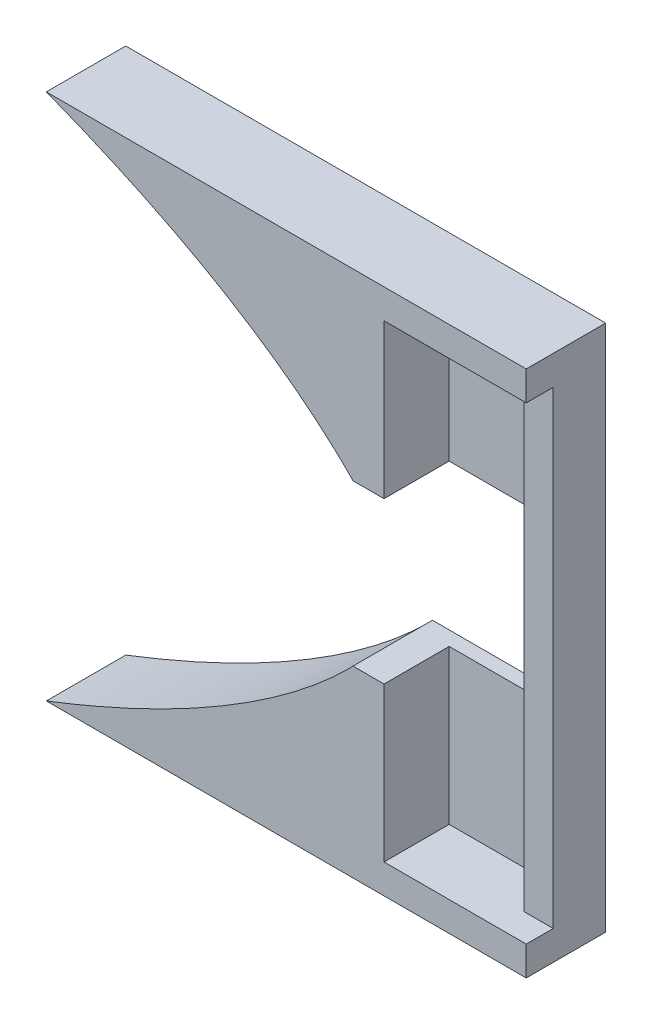
from build123d import *

# Parameters (mm, degrees)
BOSS_EXTRUDE1_DEPTH = 3.3
SKETCH2_W           = 7.1
SKETCH2_H           = 9.7
BOSS_EXTRUDE2_DEPTH = 0.9
BOSS_EXTRUDE3_DEPTH = 1.7


with BuildPart() as part:
    # Sketch1 → Boss-Extrude1 (new body)
    with BuildSketch(Plane.XY):
        with BuildLine():
            Line((57.315911484, 16.6), (34.644864201, 16.6))
            add(Edge.make_bspline(
                [(38.29556789, 15.1), (37.098221073, 15.62404419), (35.878697194, 16.123957864), (34.644864201, 16.6)],
                knots=[0.303308677, 0.303308677, 0.303308677, 0.303308677, 0.363483136, 0.363483136, 0.363483136, 0.363483136], degree=3))
            Line((38.29556789, 15.1), (58.028235271, 15.1))
            add(Edge.make_bspline(
                [(58.028235271, 15.1), (57.812878468, 15.594922403), (57.575647456, 16.094915482), (57.315911484, 16.6)],
                knots=[1.426893222, 1.426893222, 1.426893222, 1.426893222, 1.452839647, 1.452839647, 1.452839647, 1.452839647], degree=3))
        make_face()
        with BuildLine():
            Line((64.85, 16.6), (57.315911484, 16.6))
            add(Edge.make_bspline(
                [(58.028235271, 15.1), (57.812878468, 15.594922403), (57.575647456, 16.094915482), (57.315911484, 16.6)],
                knots=[1.426893222, 1.426893222, 1.426893222, 1.426893222, 1.452839647, 1.452839647, 1.452839647, 1.452839647], degree=3))
            Line((58.028235271, 15.1), (63.35, 15.1))
            Line((63.35, 15.1), (63.35, 7.210091206))
            add(Edge.make_bspline(
                [(63.35, 7.210091206), (63.846734552, 7.128818212), (64.346729159, 7.047274139), (64.85, 6.965459519)],
                knots=[2.014857734, 2.014857734, 2.014857734, 2.014857734, 2.022509587, 2.022509587, 2.022509587, 2.022509587], degree=3))
            Line((64.85, 6.965459519), (64.85, 16.6))
        make_face()
        with BuildLine():
            add(Edge.make_bspline(
                [(55.9, -8.449641541), (53.219410431, -8.903431774), (50.645090889, -9.348060462), (48.173910637, -9.783424554)],
                knots=[-0.975271105, -0.975271105, -0.975271105, -0.975271105, -0.931011535, -0.931011535, -0.931011535, -0.931011535], degree=3))
            add(Edge.make_bspline(
                [(48.17391063, -9.783424538), (50.235379211, -8.397456689), (52.10175446, -6.904847258), (53.703300859, -5.303300859)],
                knots=[0.875469321, 0.875469321, 0.875469321, 0.875469321, 1, 1, 1, 1], degree=3))
            add(Edge.make_bspline(
                [(38.29556789, -15.1), (44.330780941, -12.458561206), (49.802551874, -9.204049844), (53.703300859, -5.303300859)],
                knots=[0.696691323, 0.696691323, 0.696691323, 0.696691323, 1, 1, 1, 1], degree=3))
            Line((38.29556789, -15.1), (58.028235271, -15.1))
            add(Edge.make_bspline(
                [(58.028235271, -15.1), (58.079123886, -14.983050292), (58.128791104, -14.866383717), (58.177245249, -14.75)],
                knots=[-0.426893222, -0.426893222, -0.426893222, -0.426893222, -0.420762106, -0.420762106, -0.420762106, -0.420762106], degree=3))
            Line((58.177245249, -14.75), (55.9, -14.75))
            Line((55.9, -14.75), (55.9, -8.449641541))
        make_face()
        with BuildLine():
            add(Edge.make_bspline(
                [(48.17391063, -9.783424538), (50.235379211, -8.397456689), (52.10175446, -6.904847258), (53.703300859, -5.303300859)],
                knots=[0.875469321, 0.875469321, 0.875469321, 0.875469321, 1, 1, 1, 1], degree=3))
            add(Edge.make_bspline(
                [(55.9, -8.449641541), (53.219410431, -8.903431774), (50.645090889, -9.348060462), (48.173910637, -9.783424554)],
                knots=[-0.975271105, -0.975271105, -0.975271105, -0.975271105, -0.931011535, -0.931011535, -0.931011535, -0.931011535], degree=3))
            Line((55.9, -8.449641541), (55.9, -5.05))
            Line((55.9, -5.05), (53.953496898, -5.05))
            add(Edge.make_bspline(
                [(53.703300859, -5.303300859), (53.787433741, -5.219167977), (53.87083579, -5.134734468), (53.953496898, -5.05)],
                knots=[1, 1, 1, 1, 1.00654188, 1.00654188, 1.00654188, 1.00654188], degree=3))
        make_face()
        with BuildLine():
            add(Edge.make_bspline(
                [(53.703300859, 5.303300859), (52.10175446, 6.904847258), (50.235379211, 8.397456689), (48.17391063, 9.783424538)],
                knots=[0, 0, 0, 0, 0.124530679, 0.124530679, 0.124530679, 0.124530679], degree=3))
            add(Edge.make_bspline(
                [(53.953496898, 5.05), (53.87083579, 5.134734468), (53.787433741, 5.219167977), (53.703300859, 5.303300859)],
                knots=[-0.00654188, -0.00654188, -0.00654188, -0.00654188, 0, 0, 0, 0], degree=3))
            Line((53.953496898, 5.05), (55.9, 5.05))
            Line((55.9, 5.05), (55.9, 8.449641541))
            add(Edge.make_bspline(
                [(48.173910637, 9.783424554), (50.645090889, 9.348060462), (53.219410431, 8.903431774), (55.9, 8.449641541)],
                knots=[1.931011535, 1.931011535, 1.931011535, 1.931011535, 1.975271105, 1.975271105, 1.975271105, 1.975271105], degree=3))
        make_face()
        with BuildLine():
            add(Edge.make_bspline(
                [(53.953496898, 5.05), (53.87083579, 5.134734468), (53.787433741, 5.219167977), (53.703300859, 5.303300859)],
                knots=[-0.00654188, -0.00654188, -0.00654188, -0.00654188, 0, 0, 0, 0], degree=3))
            ThreePointArc((53.703300859, 5.303300859), (53.825650241, 5.178061362), (53.945042831, 5.05))
            Line((53.945042831, 5.05), (53.953496898, 5.05))
        make_face()
        with BuildLine():
            Line((58.028235271, 15.1), (38.29556789, 15.1))
            add(Edge.make_bspline(
                [(48.17391063, 9.783424538), (45.214437276, 11.773139517), (41.852878937, 13.543067491), (38.29556789, 15.1)],
                knots=[0.124530679, 0.124530679, 0.124530679, 0.124530679, 0.303308677, 0.303308677, 0.303308677, 0.303308677], degree=3))
            add(Edge.make_bspline(
                [(48.173910637, 9.783424554), (50.645090889, 9.348060462), (53.219410431, 8.903431774), (55.9, 8.449641541)],
                knots=[1.931011535, 1.931011535, 1.931011535, 1.931011535, 1.975271105, 1.975271105, 1.975271105, 1.975271105], degree=3))
            Line((55.9, 8.449641541), (55.9, 14.75))
            Line((55.9, 14.75), (58.177245249, 14.75))
            add(Edge.make_bspline(
                [(58.177245249, 14.75), (58.128791104, 14.866383717), (58.079123886, 14.983050292), (58.028235271, 15.1)],
                knots=[1.420762106, 1.420762106, 1.420762106, 1.420762106, 1.426893222, 1.426893222, 1.426893222, 1.426893222], degree=3))
        make_face()
        with BuildLine():
            Line((63.35, 15.1), (58.028235271, 15.1))
            add(Edge.make_bspline(
                [(58.177245249, 14.75), (58.128791104, 14.866383717), (58.079123886, 14.983050292), (58.028235271, 15.1)],
                knots=[1.420762106, 1.420762106, 1.420762106, 1.420762106, 1.426893222, 1.426893222, 1.426893222, 1.426893222], degree=3))
            Line((58.177245249, 14.75), (63, 14.75))
            Line((63, 14.75), (63, 7.267399796))
            add(Edge.make_bspline(
                [(63, 7.267399796), (63.116486418, 7.248311937), (63.233153014, 7.229209071), (63.35, 7.210091206)],
                knots=[2.013057787, 2.013057787, 2.013057787, 2.013057787, 2.014857734, 2.014857734, 2.014857734, 2.014857734], degree=3))
            Line((63.35, 7.210091206), (63.35, 15.1))
        make_face()
        with BuildLine():
            add(Edge.make_bspline(
                [(34.644864201, -16.6), (35.878697194, -16.123957864), (37.098221074, -15.62404419), (38.29556789, -15.1)],
                knots=[0.636516864, 0.636516864, 0.636516864, 0.636516864, 0.696691323, 0.696691323, 0.696691323, 0.696691323], degree=3))
            Line((34.644864201, -16.6), (57.315911484, -16.6))
            add(Edge.make_bspline(
                [(57.315911484, -16.6), (57.575647456, -16.094915482), (57.812878468, -15.594922403), (58.028235271, -15.1)],
                knots=[-0.452839647, -0.452839647, -0.452839647, -0.452839647, -0.426893222, -0.426893222, -0.426893222, -0.426893222], degree=3))
            Line((58.028235271, -15.1), (38.29556789, -15.1))
        make_face()
        with BuildLine():
            Line((64.85, -6.965459519), (64.85, 6.965459519))
            add(Edge.make_bspline(
                [(63.35, 7.210091206), (63.846734552, 7.128818212), (64.346729159, 7.047274139), (64.85, 6.965459519)],
                knots=[2.014857734, 2.014857734, 2.014857734, 2.014857734, 2.022509587, 2.022509587, 2.022509587, 2.022509587], degree=3))
            Line((63.35, 7.210091206), (63.35, -7.210091206))
            add(Edge.make_bspline(
                [(64.85, -6.965459519), (64.346729159, -7.047274139), (63.846734552, -7.128818212), (63.35, -7.210091206)],
                knots=[-1.022509587, -1.022509587, -1.022509587, -1.022509587, -1.014857734, -1.014857734, -1.014857734, -1.014857734], degree=3))
        make_face()
        with BuildLine():
            add(Edge.make_bspline(
                [(57.315911484, -16.6), (57.575647456, -16.094915482), (57.812878468, -15.594922403), (58.028235271, -15.1)],
                knots=[-0.452839647, -0.452839647, -0.452839647, -0.452839647, -0.426893222, -0.426893222, -0.426893222, -0.426893222], degree=3))
            Line((57.315911484, -16.6), (64.85, -16.6))
            Line((64.85, -16.6), (64.85, -6.965459519))
            add(Edge.make_bspline(
                [(64.85, -6.965459519), (64.346729159, -7.047274139), (63.846734552, -7.128818212), (63.35, -7.210091206)],
                knots=[-1.022509587, -1.022509587, -1.022509587, -1.022509587, -1.014857734, -1.014857734, -1.014857734, -1.014857734], degree=3))
            Line((63.35, -7.210091206), (63.35, -15.1))
            Line((63.35, -15.1), (58.028235271, -15.1))
        make_face()
        with BuildLine():
            Line((63.35, -7.210091206), (63.35, 7.210091206))
            add(Edge.make_bspline(
                [(63, 7.267399796), (63.116486418, 7.248311937), (63.233153014, 7.229209071), (63.35, 7.210091206)],
                knots=[2.013057787, 2.013057787, 2.013057787, 2.013057787, 2.014857734, 2.014857734, 2.014857734, 2.014857734], degree=3))
            Line((63, 7.267399796), (63, -7.267399796))
            add(Edge.make_bspline(
                [(63.35, -7.210091206), (63.233153014, -7.229209071), (63.116486418, -7.248311937), (63, -7.267399796)],
                knots=[-1.014857734, -1.014857734, -1.014857734, -1.014857734, -1.013057787, -1.013057787, -1.013057787, -1.013057787], degree=3))
        make_face()
        with BuildLine():
            Line((53.953496898, -5.05), (53.945042831, -5.05))
            ThreePointArc((53.945042831, -5.05), (53.825650241, -5.178061362), (53.703300859, -5.303300859))
            add(Edge.make_bspline(
                [(53.703300859, -5.303300859), (53.787433741, -5.219167977), (53.87083579, -5.134734468), (53.953496898, -5.05)],
                knots=[1, 1, 1, 1, 1.00654188, 1.00654188, 1.00654188, 1.00654188], degree=3))
        make_face()
        with BuildLine():
            add(Edge.make_bspline(
                [(58.028235271, -15.1), (58.079123886, -14.983050292), (58.128791104, -14.866383717), (58.177245249, -14.75)],
                knots=[-0.426893222, -0.426893222, -0.426893222, -0.426893222, -0.420762106, -0.420762106, -0.420762106, -0.420762106], degree=3))
            Line((58.028235271, -15.1), (63.35, -15.1))
            Line((63.35, -15.1), (63.35, -7.210091206))
            add(Edge.make_bspline(
                [(63.35, -7.210091206), (63.233153014, -7.229209071), (63.116486418, -7.248311937), (63, -7.267399796)],
                knots=[-1.014857734, -1.014857734, -1.014857734, -1.014857734, -1.013057787, -1.013057787, -1.013057787, -1.013057787], degree=3))
            Line((63, -7.267399796), (63, -14.75))
            Line((63, -14.75), (58.177245249, -14.75))
        make_face()
    extrude(amount=-BOSS_EXTRUDE1_DEPTH)

    # Sketch2 → Boss-Extrude2 (add)
    with BuildSketch(Plane(origin=(0, 0, -3.3), x_dir=(-1, 0, 0), z_dir=(0, 0, -1))):
        with Locations((-59.45, -9.9)):
            Rectangle(SKETCH2_W, SKETCH2_H)
        with Locations((-59.45, 9.9)):
            Rectangle(SKETCH2_W, SKETCH2_H)
    extrude(amount=-BOSS_EXTRUDE2_DEPTH)

    # Sketch3 → Boss-Extrude3 (add)
    with BuildSketch(Plane.XY):
        with BuildLine():
            Line((58.177245249, 14.75), (63, 14.75))
            Line((63, 14.75), (64.85, 14.75))
            Line((64.85, 14.75), (64.85, 16.6))
            Line((64.85, 16.6), (57.315911484, 16.6))
            add(Edge.make_bspline(
                [(57.315911484, 16.6), (57.637022826, 15.975564476), (57.923736792, 15.358910886), (58.177245249, 14.75)],
                knots=[0.183677217, 0.183677217, 0.183677217, 0.183677217, 0.215754758, 0.215754758, 0.215754758, 0.215754758], degree=3))
        make_face()
        with BuildLine():
            Line((57.315911484, 16.6), (34.644864201, 16.6))
            add(Edge.make_bspline(
                [(34.644864201, 16.6), (39.544408477, 14.709639199), (44.218315219, 12.442852923), (48.173910631, 9.783424537)],
                knots=[0, 0, 0, 0, 0.238952457, 0.238952457, 0.238952457, 0.238952457], degree=3))
            add(Edge.make_bspline(
                [(55.9, 8.449641541), (53.219410431, 8.903431774), (50.64509089, 9.348060461), (48.173910638, 9.783424554)],
                knots=[-1.611787969, -1.611787969, -1.611787969, -1.611787969, -1.567528399, -1.567528399, -1.567528399, -1.567528399], degree=3))
            Line((55.9, 8.449641541), (55.9, 14.75))
            Line((55.9, 14.75), (58.177245249, 14.75))
            add(Edge.make_bspline(
                [(57.315911484, 16.6), (57.637022826, 15.975564476), (57.923736792, 15.358910886), (58.177245249, 14.75)],
                knots=[0.183677217, 0.183677217, 0.183677217, 0.183677217, 0.215754758, 0.215754758, 0.215754758, 0.215754758], degree=3))
        make_face()
        with BuildLine():
            Line((55.9, 5.05), (55.9, 8.449641541))
            add(Edge.make_bspline(
                [(55.9, 8.449641541), (53.219410431, 8.903431774), (50.64509089, 9.348060461), (48.173910638, 9.783424554)],
                knots=[-1.611787969, -1.611787969, -1.611787969, -1.611787969, -1.567528399, -1.567528399, -1.567528399, -1.567528399], degree=3))
            add(Edge.make_bspline(
                [(48.173910631, 9.783424537), (50.235379212, 8.397456689), (52.10175446, 6.904847257), (53.703300859, 5.303300859)],
                knots=[0.238952457, 0.238952457, 0.238952457, 0.238952457, 0.363483136, 0.363483136, 0.363483136, 0.363483136], degree=3))
            add(Edge.make_bspline(
                [(53.703300859, 5.303300859), (53.787433741, 5.219167977), (53.87083579, 5.134734468), (53.953496898, 5.05)],
                knots=[0.363483136, 0.363483136, 0.363483136, 0.363483136, 0.370025016, 0.370025016, 0.370025016, 0.370025016], degree=3))
            Line((53.953496898, 5.05), (55.9, 5.05))
        make_face()
        with BuildLine():
            Line((64.85, -14.75), (63, -14.75))
            Line((63, -14.75), (58.177245249, -14.75))
            add(Edge.make_bspline(
                [(58.177245249, -14.75), (57.923736792, -15.358910886), (57.637022826, -15.975564476), (57.315911484, -16.6)],
                knots=[0.784245242, 0.784245242, 0.784245242, 0.784245242, 0.816322783, 0.816322783, 0.816322783, 0.816322783], degree=3))
            Line((57.315911484, -16.6), (64.85, -16.6))
            Line((64.85, -16.6), (64.85, -14.75))
        make_face()
        with BuildLine():
            add(Edge.make_bspline(
                [(53.703300859, 5.303300859), (53.787433741, 5.219167977), (53.87083579, 5.134734468), (53.953496898, 5.05)],
                knots=[0.363483136, 0.363483136, 0.363483136, 0.363483136, 0.370025016, 0.370025016, 0.370025016, 0.370025016], degree=3))
            ThreePointArc((53.703300859, 5.303300859), (53.825650241, 5.178061362), (53.945042831, 5.05))
            Line((53.945042831, 5.05), (53.953496898, 5.05))
        make_face()
        with BuildLine():
            add(Edge.make_bspline(
                [(53.953496898, -5.05), (53.87083579, -5.134734468), (53.787433741, -5.219167977), (53.703300859, -5.303300859)],
                knots=[0.629974984, 0.629974984, 0.629974984, 0.629974984, 0.636516864, 0.636516864, 0.636516864, 0.636516864], degree=3))
            Line((53.953496898, -5.05), (53.945042831, -5.05))
            ThreePointArc((53.945042831, -5.05), (53.825650241, -5.178061362), (53.703300859, -5.303300859))
        make_face()
        with BuildLine():
            add(Edge.make_bspline(
                [(48.173910631, -9.783424537), (44.218315219, -12.442852923), (39.544408477, -14.709639199), (34.644864201, -16.6)],
                knots=[0.761047543, 0.761047543, 0.761047543, 0.761047543, 1, 1, 1, 1], degree=3))
            Line((34.644864201, -16.6), (57.315911484, -16.6))
            add(Edge.make_bspline(
                [(58.177245249, -14.75), (57.923736792, -15.358910886), (57.637022826, -15.975564476), (57.315911484, -16.6)],
                knots=[0.784245242, 0.784245242, 0.784245242, 0.784245242, 0.816322783, 0.816322783, 0.816322783, 0.816322783], degree=3))
            Line((58.177245249, -14.75), (55.9, -14.75))
            Line((55.9, -14.75), (55.9, -8.449641541))
            add(Edge.make_bspline(
                [(48.173910638, -9.783424554), (50.64509089, -9.348060461), (53.219410431, -8.903431774), (55.9, -8.449641541)],
                knots=[2.567528399, 2.567528399, 2.567528399, 2.567528399, 2.611787969, 2.611787969, 2.611787969, 2.611787969], degree=3))
        make_face()
        with BuildLine():
            Line((55.9, -5.05), (53.953496898, -5.05))
            add(Edge.make_bspline(
                [(53.953496898, -5.05), (53.87083579, -5.134734468), (53.787433741, -5.219167977), (53.703300859, -5.303300859)],
                knots=[0.629974984, 0.629974984, 0.629974984, 0.629974984, 0.636516864, 0.636516864, 0.636516864, 0.636516864], degree=3))
            add(Edge.make_bspline(
                [(53.703300859, -5.303300859), (52.10175446, -6.904847257), (50.235379212, -8.397456689), (48.173910631, -9.783424537)],
                knots=[0.636516864, 0.636516864, 0.636516864, 0.636516864, 0.761047543, 0.761047543, 0.761047543, 0.761047543], degree=3))
            add(Edge.make_bspline(
                [(48.173910638, -9.783424554), (50.64509089, -9.348060461), (53.219410431, -8.903431774), (55.9, -8.449641541)],
                knots=[2.567528399, 2.567528399, 2.567528399, 2.567528399, 2.611787969, 2.611787969, 2.611787969, 2.611787969], degree=3))
            Line((55.9, -8.449641541), (55.9, -5.05))
        make_face()
    extrude(amount=BOSS_EXTRUDE3_DEPTH)


solid = part.part
